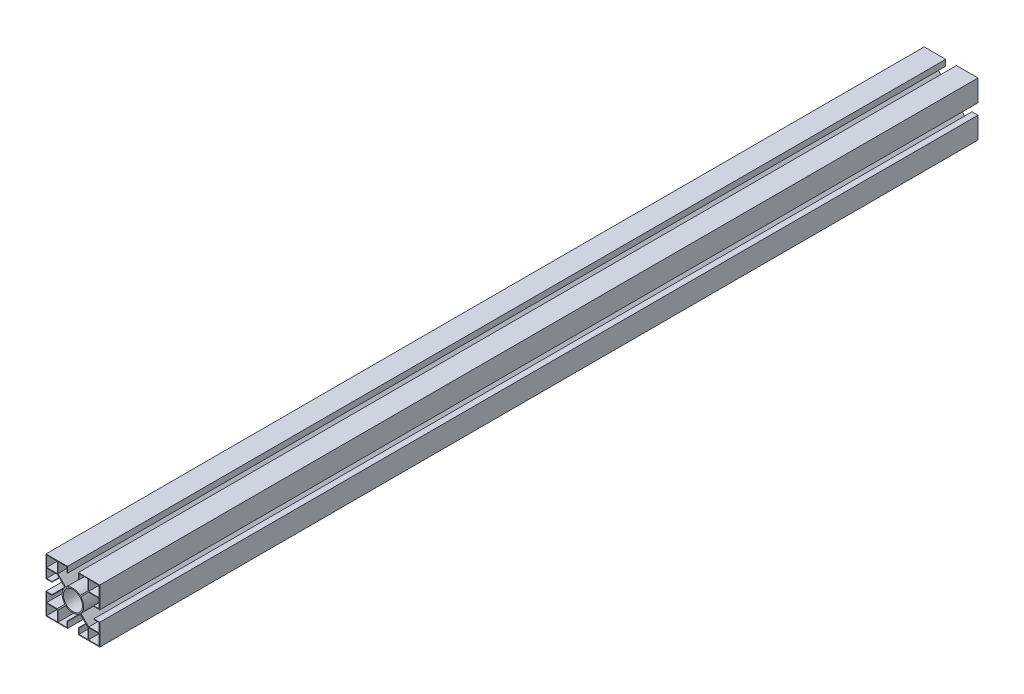
from build123d import *

# Parameters (mm, degrees)
ESBO_O1_W                = 9
ESBO_O1_H                = 9
ESBO_O1_R                = 8
RESSALTO_EXTRUS_O4_DEPTH = 734.5


with BuildPart() as part:
    # Esboço1 → Ressalto-extrusão4 (new body)
    with BuildSketch(Plane.XY):
        with BuildLine():
            Line((-4.5, 22.5), (-22.5, 22.5))
            Line((-22.5, 22.5), (-22.5, 4.5))
            Line((-22.5, 4.5), (-17.5, 4.5))
            Line((-17.5, 4.5), (-17.5, 5))
            Line((-17.5, 5), (-22, 5))
            Line((-22, 5), (-22, 12.5))
            Line((-22, 12.5), (-13.207106781, 12.5))
            Line((-13.207106781, 12.5), (-6.707685904, 6.000579123))
            ThreePointArc((-6.707685904, 6.000579123), (-9, 0), (-6.707685904, -6.000579123))
            Line((-6.707685904, -6.000579123), (-13.207106781, -12.5))
            Line((-13.207106781, -12.5), (-22, -12.5))
            Line((-22, -12.5), (-22, -5))
            Line((-22, -5), (-17.5, -5))
            Line((-17.5, -5), (-17.5, -4.5))
            Line((-17.5, -4.5), (-22.5, -4.5))
            Line((-22.5, -4.5), (-22.5, -22.5))
            Line((-22.5, -22.5), (-4.5, -22.5))
            Line((-4.5, -22.5), (-4.5, -17.5))
            Line((-4.5, -17.5), (-5, -17.5))
            Line((-5, -17.5), (-5, -22))
            Line((-5, -22), (-12.5, -22))
            Line((-12.5, -22), (-12.5, -13.207106781))
            Line((-12.5, -13.207106781), (-6.000579123, -6.707685904))
            ThreePointArc((-6.000579123, -6.707685904), (0, -9), (6.000579123, -6.707685904))
            Line((6.000579123, -6.707685904), (12.5, -13.207106781))
            Line((12.5, -13.207106781), (12.5, -22))
            Line((12.5, -22), (5, -22))
            Line((5, -22), (5, -17.5))
            Line((5, -17.5), (4.5, -17.5))
            Line((4.5, -17.5), (4.5, -22.5))
            Line((4.5, -22.5), (22.5, -22.5))
            Line((22.5, -22.5), (22.5, -4.5))
            Line((22.5, -4.5), (17.5, -4.5))
            Line((17.5, -4.5), (17.5, -5))
            Line((17.5, -5), (22, -5))
            Line((22, -5), (22, -12.5))
            Line((22, -12.5), (13.207106781, -12.5))
            Line((13.207106781, -12.5), (6.707685904, -6.000579123))
            ThreePointArc((6.707685904, -6.000579123), (9, 0), (6.707685904, 6.000579123))
            Line((6.707685904, 6.000579123), (13.207106781, 12.5))
            Line((13.207106781, 12.5), (22, 12.5))
            Line((22, 12.5), (22, 5))
            Line((22, 5), (17.5, 5))
            Line((17.5, 5), (17.5, 4.5))
            Line((17.5, 4.5), (22.5, 4.5))
            Line((22.5, 4.5), (22.5, 22.5))
            Line((22.5, 22.5), (4.5, 22.5))
            Line((4.5, 22.5), (4.5, 17.5))
            Line((4.5, 17.5), (5, 17.5))
            Line((5, 17.5), (5, 22))
            Line((5, 22), (12.5, 22))
            Line((12.5, 22), (12.5, 13.207106781))
            Line((12.5, 13.207106781), (6.000579123, 6.707685904))
            ThreePointArc((6.000579123, 6.707685904), (0, 9), (-6.000579123, 6.707685904))
            Line((-6.000579123, 6.707685904), (-12.5, 13.207106781))
            Line((-12.5, 13.207106781), (-12.5, 22))
            Line((-12.5, 22), (-5, 22))
            Line((-5, 22), (-5, 17.5))
            Line((-5, 17.5), (-4.5, 17.5))
            Line((-4.5, 17.5), (-4.5, 22.5))
        make_face()
        with Locations((17.5, 17.5)):
            Rectangle(ESBO_O1_W, ESBO_O1_H, mode=Mode.SUBTRACT)
        with Locations((-17.5, -17.5)):
            Rectangle(ESBO_O1_W, ESBO_O1_H, mode=Mode.SUBTRACT)
        with Locations((17.5, -17.5)):
            Rectangle(ESBO_O1_W, ESBO_O1_H, mode=Mode.SUBTRACT)
        with Locations((-17.5, 17.5)):
            Rectangle(ESBO_O1_W, ESBO_O1_H, mode=Mode.SUBTRACT)
        Circle(ESBO_O1_R, mode=Mode.SUBTRACT)
    extrude(amount=RESSALTO_EXTRUS_O4_DEPTH)


solid = part.part
